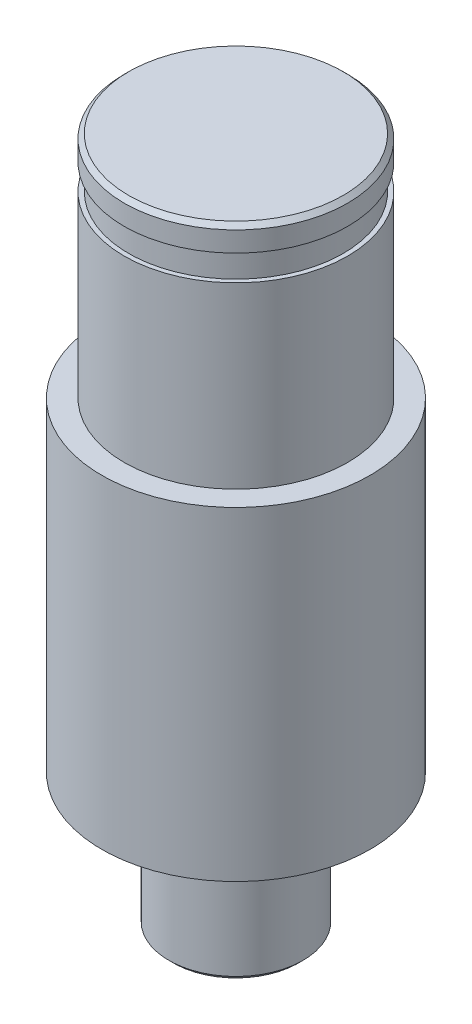
from build123d import *

# Parameters (mm, degrees)
CHAMFER_1_SIZE = 0.2


with BuildPart() as part:
    # 草圖1 → 旋轉1 (revolve)
    with BuildSketch(Plane.XY):
        Polygon((3, 0), (3, -6), (0, -6), (0, 24.75), (5, 24.75), (5, 23.65), (4.8, 23.65), (4.8, 22.5), (5, 22.5), (5, 14.5), (6, 14.5), (6, 0), align=None)
    revolve(axis=Axis((0, 0, 0), (0, 1, 0)))

    # 導角1
    chamfer_1_edges = [part.edges().sort_by_distance(p)[0] for p in [
        (-5, 24.75, 0),
        (-3, -6, 0),
    ]]
    chamfer(chamfer_1_edges, length=CHAMFER_1_SIZE)


solid = part.part
